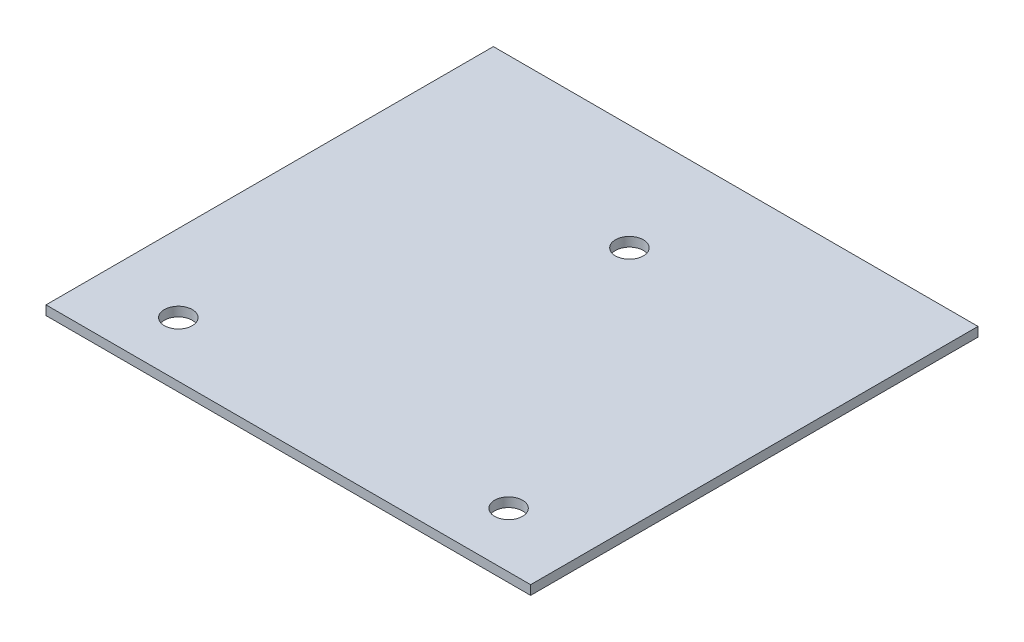
from build123d import *

# Parameters (mm, degrees)
SKETCH1_W           = 660.4
SKETCH1_H           = 609.6
BOSS_EXTRUDE1_DEPTH = 12.7
SKETCH5_R           = 19.05
CUT_EXTRUDE2_DEPTH  = 13.7


with BuildPart() as part:
    # Sketch1 → Boss-Extrude1 (new body)
    with BuildSketch(Plane(origin=(0, 0, 0), x_dir=(1, 0, 0), z_dir=(0, 1, 0))):
        with Locations((330.2, 304.8)):
            Rectangle(SKETCH1_W, SKETCH1_H)
    extrude(amount=BOSS_EXTRUDE1_DEPTH)

    # Sketch5 → Cut-Extrude2 (cut, through all)
    with BuildSketch(Plane(origin=(0, 12.7, 0), x_dir=(1, 0, 0), z_dir=(0, 1, 0))):
        with Locations((105.2, 75.116646637)):
            Circle(SKETCH5_R)
        with Locations((555.2, 75.116646637)):
            Circle(SKETCH5_R)
        with Locations((330.2, 464.82807834)):
            Circle(SKETCH5_R)
    extrude(amount=-CUT_EXTRUDE2_DEPTH, mode=Mode.SUBTRACT)


solid = part.part
